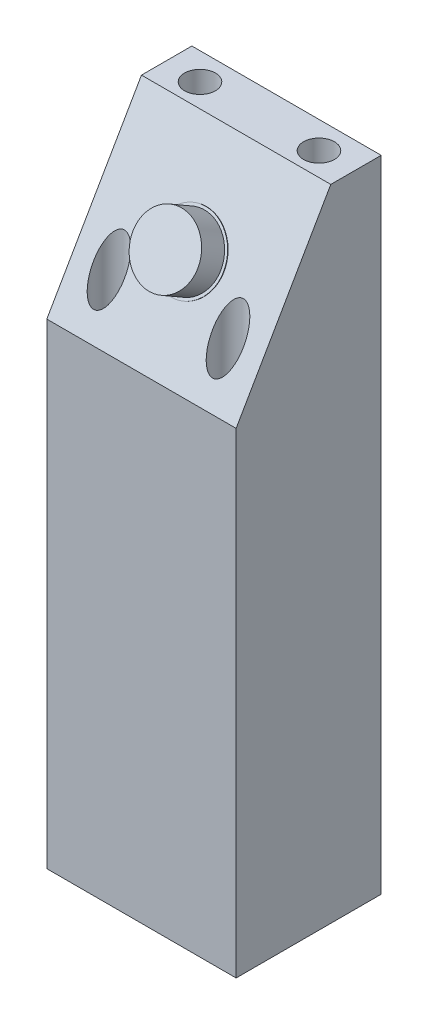
from build123d import *

# Parameters (mm, degrees)
AUFSATZ_LINEAR_AUSTRAGEN1_DEPTH      = 35
SKIZZE3_R                            = 6
AUFSATZ_LINEAR_AUSTRAGEN2_DEPTH      = 5
SKIZZE4_R                            = 6.5
AUFSATZ_LINEAR_AUSTRAGEN3_DEPTH      = 0.1
SKIZZE7_R                            = 2.85
SCHNITT_LINEAR_AUSTRAGEN1_DEPTH      = 114.810889132
F_3_4_3_4_DURCHMESSER_BOHRUNG1_D     = 3.4
F_3_4_3_4_DURCHMESSER_BOHRUNG1_DEPTH = 4.5


with BuildPart() as part:
    # Skizze1 → Aufsatz-Linear austragen1 (new body)
    with BuildSketch(Plane(origin=(0, 0, 0), x_dir=(0, 0, -1), z_dir=(1, 0, 0))):
        Polygon((0, 0), (17.5, 0), (26.82, 0), (26.82, 118.310889132), (17.5, 118.310889132), (0, 88), align=None)
    extrude(amount=AUFSATZ_LINEAR_AUSTRAGEN1_DEPTH)

    # Skizze3 → Aufsatz-Linear austragen2 (add)
    with BuildSketch(Plane(origin=(0, 22, 38.105117767), x_dir=(1, 0, 0), z_dir=(0, 0.5, 0.866025404))):
        with Locations((17.5, 93.710235533)):
            Circle(SKIZZE3_R)
    extrude(amount=AUFSATZ_LINEAR_AUSTRAGEN2_DEPTH)

    # Skizze4 → Aufsatz-Linear austragen3 (add)
    with BuildSketch(Plane(origin=(0, 22, 38.105117767), x_dir=(1, 0, 0), z_dir=(0, 0.5, 0.866025404))):
        with Locations((17.5, 93.710235533)):
            Circle(SKIZZE4_R)
    extrude(amount=AUFSATZ_LINEAR_AUSTRAGEN3_DEPTH)

    # Skizze7 → Schnitt-Linear austragen1 (cut, through all)
    with BuildSketch(Plane(origin=(0, 4.5, 0), x_dir=(-1, 0, 0), z_dir=(0, -1, 0))):
        with Locations((-28.5, 5)):
            Circle(SKIZZE7_R)
        with Locations((-6.5, 5)):
            Circle(SKIZZE7_R)
        with Locations((-6.5, 21.82)):
            Circle(SKIZZE7_R)
        with Locations((-28.5, 21.82)):
            Circle(SKIZZE7_R)
    extrude(amount=-SCHNITT_LINEAR_AUSTRAGEN1_DEPTH, mode=Mode.SUBTRACT)

    # Ø3.4 (3.4) Durchmesser Bohrung1
    with Locations(Plane(origin=(6.5, 4.5, -5), x_dir=(0, 0, 1), z_dir=(0, 1, 0))):
        with Locations((0, 0), (-16.82, 0), (-16.82, 22), (0, 22)):
            Hole(F_3_4_3_4_DURCHMESSER_BOHRUNG1_D / 2, depth=F_3_4_3_4_DURCHMESSER_BOHRUNG1_DEPTH)


solid = part.part
